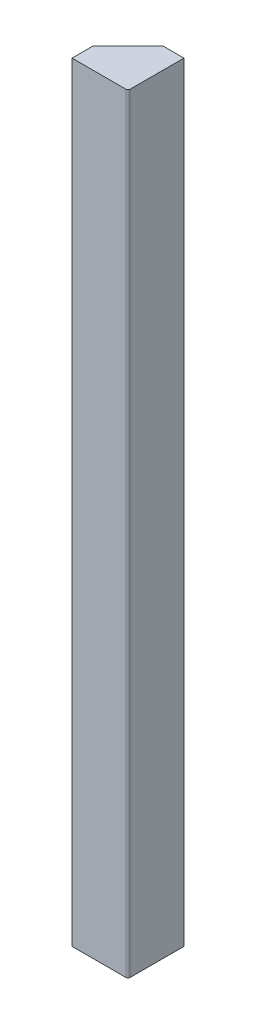
from build123d import *

# Parameters (mm, degrees)
EXTRUDE_L_NGD_DEPTH = 1100
FILLET_KANTER_R     = 3


with BuildPart() as part:
    # Sketch3 → Extrude längd (new body)
    with BuildSketch(Plane(origin=(0, 0, 0), x_dir=(1, 0, 0), z_dir=(0, 1, 0))):
        Polygon((0, -80), (80, -80), (80, 0), (50, 0), (0, -50), align=None)
    extrude(amount=EXTRUDE_L_NGD_DEPTH)

    # Fillet kanter
    fillet_kanter_edges = [part.edges().sort_by_distance(p)[0] for p in [
        (80, 550, 80),
    ]]
    fillet(fillet_kanter_edges, radius=FILLET_KANTER_R)


solid = part.part
